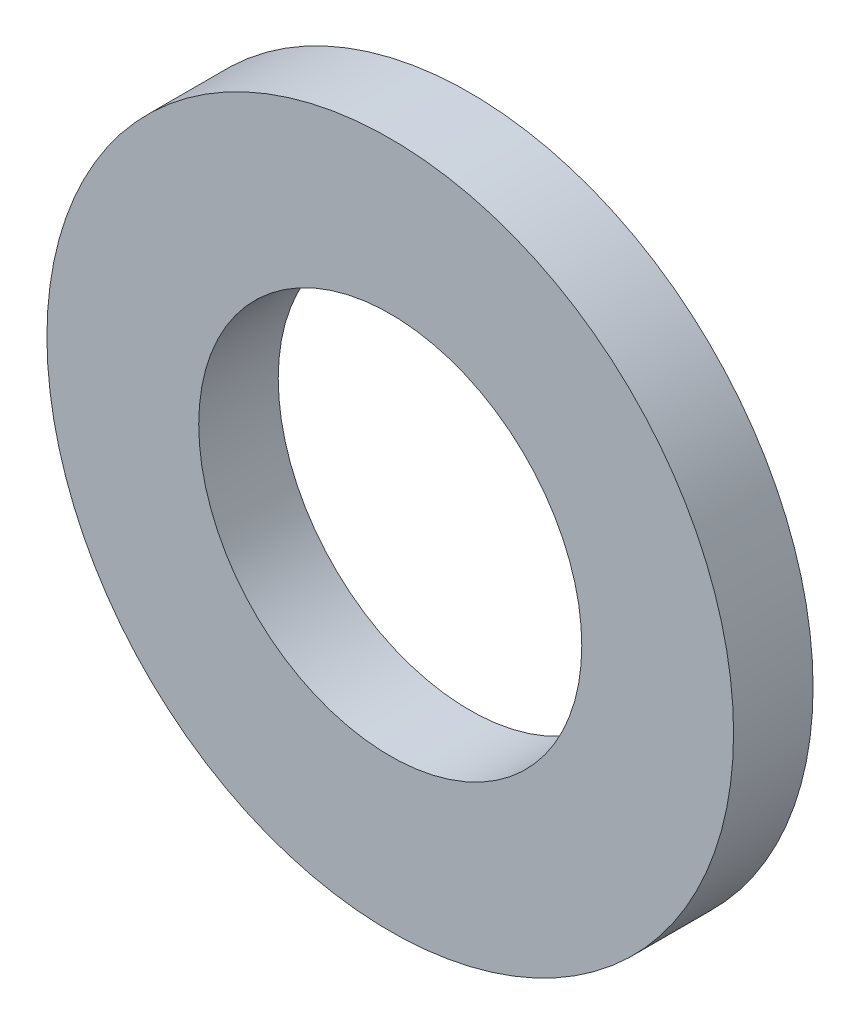
from build123d import *

# Parameters (mm, degrees)
SKETCH1_R           = 4.75
SKETCH1_R_2         = 2.65
BOSS_EXTRUDE1_DEPTH = 1.1


with BuildPart() as part:
    # Sketch1 → Boss-Extrude1 (new body)
    with BuildSketch(Plane.XY):
        Circle(SKETCH1_R)
        Circle(SKETCH1_R_2, mode=Mode.SUBTRACT)
    extrude(amount=BOSS_EXTRUDE1_DEPTH)


solid = part.part
